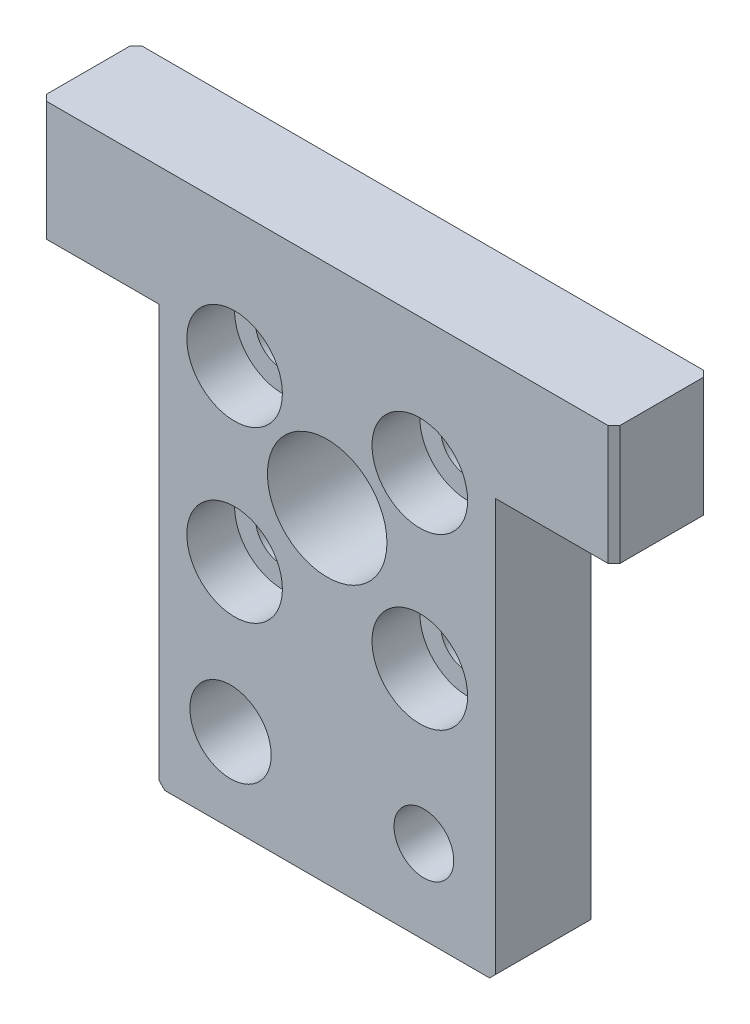
from build123d import *

# Parameters (mm, degrees)
SKETCH1_R             = 5
SKETCH1_R_2           = 2.25
BOSS_EXTRUDE1_DEPTH   = 8
SKETCH2_R             = 4
CUT_EXTRUDE1_DEPTH    = 4
M6_TAPPED_HOLE1_D     = 5
M6_TAPPED_HOLE1_DEPTH = 15
M6_TAPPED_HOLE1_TIP   = 1.502151548
M8_TAPPED_HOLE1_D     = 6.8
M8_TAPPED_HOLE1_DEPTH = 19.75
M8_TAPPED_HOLE1_TIP   = 2.042926105
CHAMFER1_SIZE         = 0.5
CHAMFER2_SIZE         = 0.5


with BuildPart() as part:
    # Sketch1 → Boss-Extrude1 (new body)
    with BuildSketch(Plane.XY):
        Polygon((21.253731343, 11.641791045), (31.164179104, 11.641791045), (31.164179104, 21.641791045), (-16.835820896, 21.641791045), (-16.835820896, 11.641791045), (-6.925373134, 11.641791045), (-6.925373134, -23.358208955), (21.253731343, -23.358208955), align=None)
        with Locations((7.164179104, 3.891791045)):
            Circle(SKETCH1_R, mode=Mode.SUBTRACT)
        with Locations((-0.585820896, -3.858208955)):
            Circle(SKETCH1_R_2, mode=Mode.SUBTRACT)
        with Locations((14.914179104, -3.858208955)):
            Circle(SKETCH1_R_2, mode=Mode.SUBTRACT)
        with Locations((14.914179104, 10.328358209)):
            Circle(SKETCH1_R_2, mode=Mode.SUBTRACT)
        with Locations((-0.585820896, 10.328358209)):
            Circle(SKETCH1_R_2, mode=Mode.SUBTRACT)
    extrude(amount=BOSS_EXTRUDE1_DEPTH)

    # Sketch2 → Cut-Extrude1 (cut)
    with BuildSketch(Plane.XY.offset(8)):
        with Locations((-0.585820896, 10.328358209)):
            Circle(SKETCH2_R)
        with Locations((14.914179104, 10.328358209)):
            Circle(SKETCH2_R)
        with Locations((14.914179104, -3.858208955)):
            Circle(SKETCH2_R)
        with Locations((-0.585820896, -3.858208955)):
            Circle(SKETCH2_R)
    extrude(amount=-CUT_EXTRUDE1_DEPTH, mode=Mode.SUBTRACT)

    # M6 Tapped Hole1
    with Locations(Plane.XY.offset(8)):
        with Locations((15.253731343, -16.358208955)):
            Hole(M6_TAPPED_HOLE1_D / 2, depth=M6_TAPPED_HOLE1_DEPTH)
            with Locations((0, 0, -(M6_TAPPED_HOLE1_DEPTH + M6_TAPPED_HOLE1_TIP / 2))):  # 118° drill point
                Cone(0, M6_TAPPED_HOLE1_D / 2, M6_TAPPED_HOLE1_TIP, mode=Mode.SUBTRACT)

    # M8 Tapped Hole1
    with Locations(Plane.XY.offset(8)):
        with Locations((-0.925373134, -16.358208955)):
            Hole(M8_TAPPED_HOLE1_D / 2, depth=M8_TAPPED_HOLE1_DEPTH)
            with Locations((0, 0, -(M8_TAPPED_HOLE1_DEPTH + M8_TAPPED_HOLE1_TIP / 2))):  # 118° drill point
                Cone(0, M8_TAPPED_HOLE1_D / 2, M8_TAPPED_HOLE1_TIP, mode=Mode.SUBTRACT)

    # Chamfer1
    chamfer1_edges = [part.edges().sort_by_distance(p)[0] for p in [
        (-16.835820896, 16.641791045, 0),
        (31.164179104, 16.641791045, 8),
        (-16.835820896, 16.641791045, 8),
        (31.164179104, 16.641791045, 0),
    ]]
    chamfer(chamfer1_edges, length=CHAMFER1_SIZE)

    # Chamfer2
    chamfer2_edges = [part.edges().sort_by_distance(p)[0] for p in [
        (21.253731343, -23.358208955, 4),
        (-6.925373134, -23.358208955, 4),
    ]]
    chamfer(chamfer2_edges, length=CHAMFER2_SIZE)


solid = part.part
